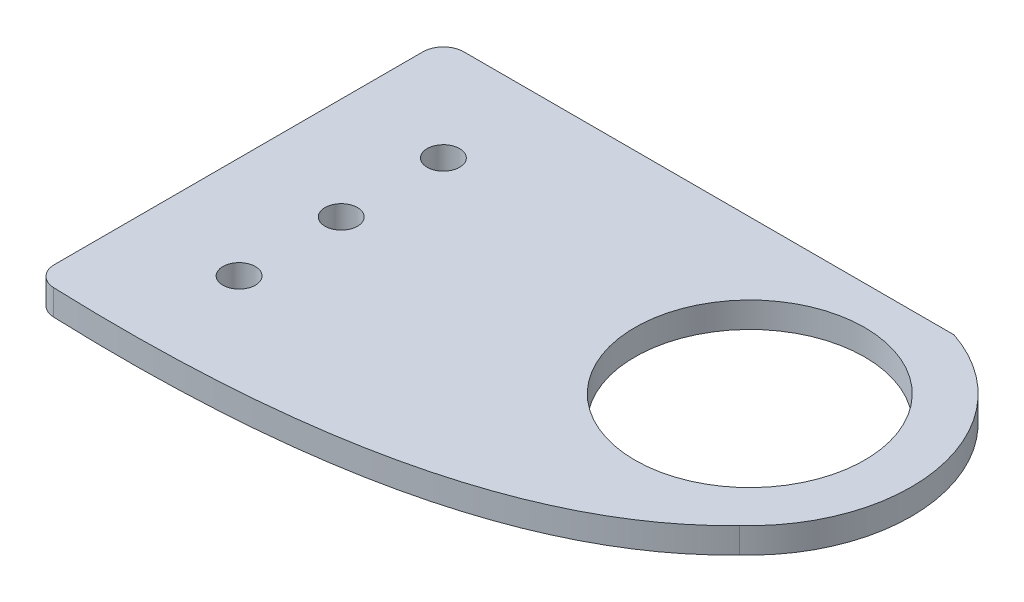
from build123d import *

# Parameters (mm, degrees)
SKETCH1_R           = 2.0193
SKETCH1_R_2         = 14.2875
BOSS_EXTRUDE1_DEPTH = 3.175
FILLET1_R           = 2.54


with BuildPart() as part:
    # Sketch1 → Boss-Extrude1 (new body)
    with BuildSketch(Plane(origin=(0, 0, 0), x_dir=(1, 0, 0), z_dir=(0, 1, 0))):
        with BuildLine():
            Line((11.158213086, 21.466758583), (-52.341786914, 21.466758583))
            Line((-52.341786914, 21.466758583), (-52.341786914, -29.333241417))
            add(Edge.make_bspline(
                [(-52.341786914, -29.333241417), (0, -31.75), (18.346437912, -12.413665165)],
                knots=[0, 0, 0, 1, 1, 1], degree=2))
            ThreePointArc((18.346437912, -12.413665165), (24.451434564, 6.58435381), (11.158213086, 21.466758583))
        make_face()
        with Locations((-39.641786914, -16.633241417)):
            Circle(SKETCH1_R, mode=Mode.SUBTRACT)
        with Locations((-39.641786914, -3.933241417)):
            Circle(SKETCH1_R, mode=Mode.SUBTRACT)
        with Locations((-39.641786914, 8.766758583)):
            Circle(SKETCH1_R, mode=Mode.SUBTRACT)
        with Locations((4.808213086, 2.416758583)):
            Circle(SKETCH1_R_2, mode=Mode.SUBTRACT)
    extrude(amount=BOSS_EXTRUDE1_DEPTH)

    # Fillet1
    fillet1_edges = [part.edges().sort_by_distance(p)[0] for p in [
        (-52.341786914, 1.5875, -21.466758583),
        (-52.341786914, 1.5875, 29.333241417),
    ]]
    fillet(fillet1_edges, radius=FILLET1_R)


solid = part.part
